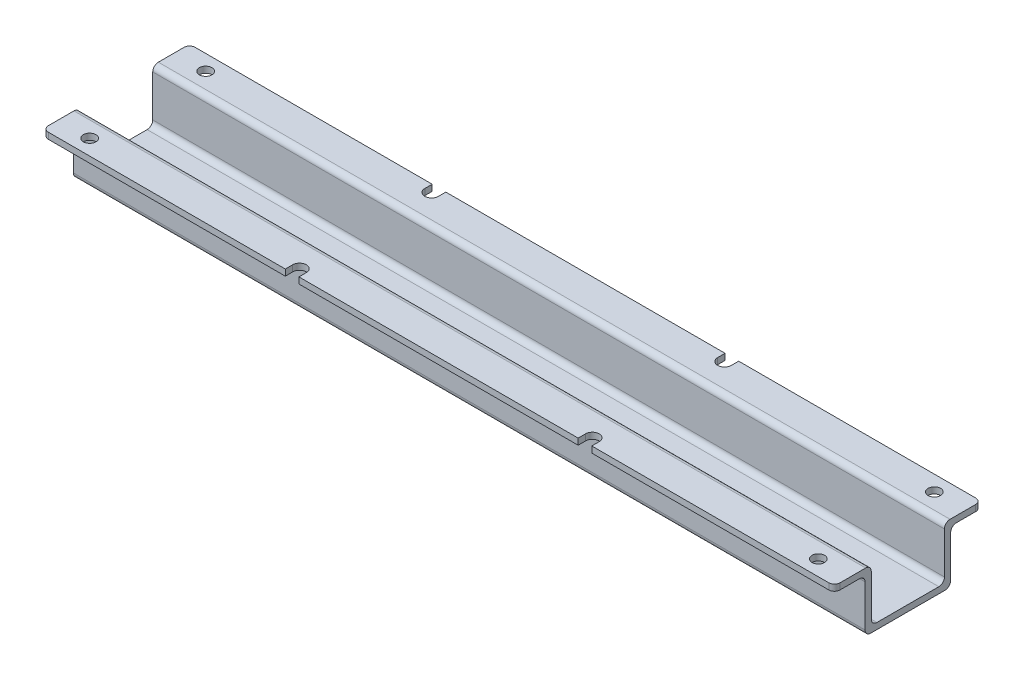
from build123d import *

# Parameters (mm, degrees)
BOSS_EXTRUDE2_DEPTH     = 203.2
FILLET4_R               = 1.44
SKETCH3_R               = 1.61
SKETCH3_R_2             = 1.735
CUT_EXTRUDE2_DEPTH      = 1
CUT_EXTRUDE2_DEPTH_BACK = 16.14


with BuildPart() as part:
    # Sketch1 → Boss-Extrude2 (new body)
    with BuildSketch(Plane(origin=(0, 0, 0), x_dir=(0, 0, -1), z_dir=(1, 0, 0))):
        with BuildLine():
            Line((-10.98, 12.11), (-10.98, 1.44))
            ThreePointArc((-10.98, 1.44), (-10.558233765, 0.421766235), (-9.54, 0))
            Line((-9.54, 0), (9.54, 0))
            ThreePointArc((9.54, 0), (10.558233765, 0.421766235), (10.98, 1.44))
            Line((10.98, 1.44), (10.98, 12.11))
            ThreePointArc((10.98, 12.11), (11.401766235, 13.128233765), (12.42, 13.55))
            Line((12.42, 13.55), (18.85, 13.55))
            Line((18.85, 13.55), (18.85, 15.14))
            Line((18.85, 15.14), (10.83, 15.14))
            ThreePointArc((10.83, 15.14), (9.811766235, 14.718233765), (9.39, 13.7))
            Line((9.39, 13.7), (9.39, 3.03))
            ThreePointArc((9.39, 3.03), (8.968233765, 2.011766235), (7.95, 1.59))
            Line((7.95, 1.59), (-7.95, 1.59))
            ThreePointArc((-7.95, 1.59), (-8.968233765, 2.011766235), (-9.39, 3.03))
            Line((-9.39, 3.03), (-9.39, 13.7))
            ThreePointArc((-9.39, 13.7), (-9.811766235, 14.718233765), (-10.83, 15.14))
            Line((-10.83, 15.14), (-18.85, 15.14))
            Line((-18.85, 15.14), (-18.85, 13.55))
            Line((-18.85, 13.55), (-12.42, 13.55))
            ThreePointArc((-12.42, 13.55), (-11.401766235, 13.128233765), (-10.98, 12.11))
        make_face()
    extrude(amount=-BOSS_EXTRUDE2_DEPTH)

    # Fillet4
    fillet4_edges = [part.edges().sort_by_distance(p)[0] for p in [
        (0, 14.345, 18.85),
        (0, 14.345, -18.85),
        (-203.2, 14.345, 18.85),
        (-203.2, 14.345, -18.85),
    ]]
    fillet(fillet4_edges, radius=FILLET4_R)

    # Sketch3 → Cut-Extrude2 (cut, two sides)
    with BuildSketch(Plane(origin=(0, 15.14, 0), x_dir=(1, 0, 0), z_dir=(0, 1, 0))) as cut_extrude2_sk:
        with Locations((-101.6, 0)):
            Circle(SKETCH3_R)
        with Locations((-26.27, 0)):
            Circle(SKETCH3_R_2)
        with Locations((-176.93, 0)):
            Circle(SKETCH3_R_2)
        with Locations((-195.11, 14.89)):
            Circle(SKETCH3_R)
        with Locations((-195.11, -14.89)):
            Circle(SKETCH3_R)
        with Locations((-8.09, 14.89)):
            Circle(SKETCH3_R)
        with Locations((-8.09, -14.89)):
            Circle(SKETCH3_R)
        with BuildLine():
            Line((-137.43, -16.95), (-137.43, -18.85))
            Line((-137.43, -18.85), (-140.93, -18.85))
            Line((-140.93, -18.85), (-140.93, -16.95))
            ThreePointArc((-140.93, -16.95), (-139.18, -15.2), (-137.43, -16.95))
        make_face()
        with BuildLine():
            Line((-140.93, 18.85), (-140.93, 16.95))
            ThreePointArc((-140.93, 16.95), (-139.18, 15.2), (-137.43, 16.95))
            Line((-137.43, 16.95), (-137.43, 18.85))
            Line((-137.43, 18.85), (-140.93, 18.85))
        make_face()
        with BuildLine():
            Line((-65.77, -16.95), (-65.77, -18.85))
            Line((-65.77, -18.85), (-62.27, -18.85))
            Line((-62.27, -18.85), (-62.27, -16.95))
            ThreePointArc((-62.27, -16.95), (-64.02, -15.2), (-65.77, -16.95))
        make_face()
        with BuildLine():
            Line((-65.77, 16.95), (-65.77, 18.85))
            Line((-65.77, 18.85), (-62.27, 18.85))
            Line((-62.27, 18.85), (-62.27, 16.95))
            ThreePointArc((-62.27, 16.95), (-64.02, 15.2), (-65.77, 16.95))
        make_face()
    extrude(amount=CUT_EXTRUDE2_DEPTH, mode=Mode.SUBTRACT)
    extrude(cut_extrude2_sk.sketch, amount=-CUT_EXTRUDE2_DEPTH_BACK, mode=Mode.SUBTRACT)


solid = part.part
